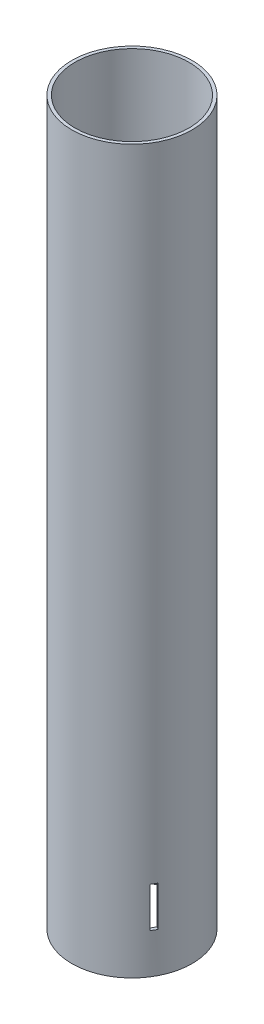
from build123d import *

# Parameters (mm, degrees)
SKETCH1_R           = 38.1
SKETCH1_R_2         = 36.1
BOSS_EXTRUDE1_DEPTH = 457.2
SKETCH2_W           = 3.81
SKETCH2_H           = 25.4
CUT_EXTRUDE1_DEPTH  = 39.1
CIRPATTERN1_COUNT   = 3


with BuildPart() as part:
    # Sketch1 → Boss-Extrude1 (new body)
    with BuildSketch(Plane(origin=(0, 0, 0), x_dir=(1, 0, 0), z_dir=(0, 1, 0))):
        Circle(SKETCH1_R)
        Circle(SKETCH1_R_2, mode=Mode.SUBTRACT)
    extrude(amount=BOSS_EXTRUDE1_DEPTH)

    # Sketch2 → Cut-Extrude1 (cut, through all)
    with BuildSketch(Plane.XY):
        with Locations((0, 38.1)):
            Rectangle(SKETCH2_W, SKETCH2_H)
    cut_extrude1 = extrude(amount=-CUT_EXTRUDE1_DEPTH, mode=Mode.SUBTRACT)

    # CirPattern1: Cut-Extrude1 ×3 about axis
    cirpattern1_axis = Axis((0, 0, 0), (0, 1, 0))
    for i in range(1, CIRPATTERN1_COUNT):
        add(cut_extrude1.rotate(cirpattern1_axis, i * 360 / CIRPATTERN1_COUNT), mode=Mode.SUBTRACT)


solid = part.part
